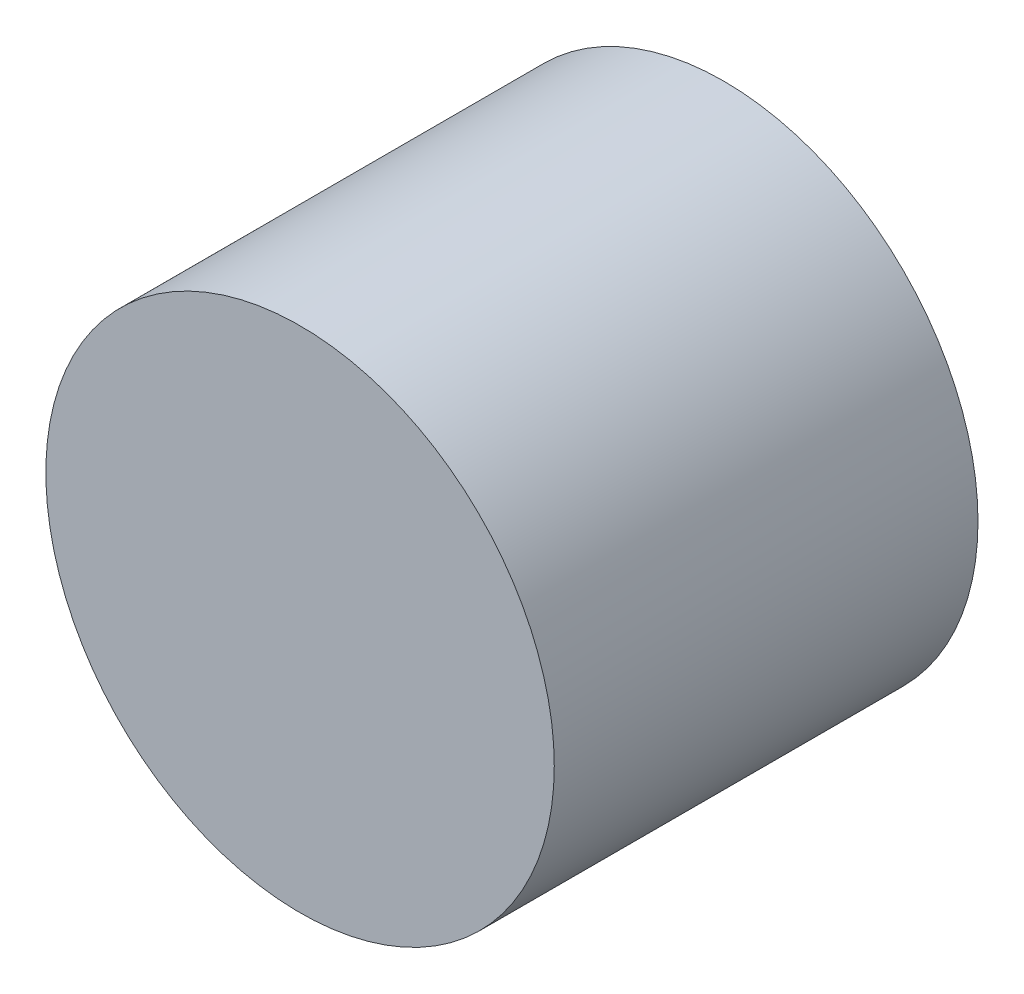
from build123d import *

# Parameters (mm, degrees)
SKETCH1_R      = 6
EXTRUDE2_DEPTH = 10


with BuildPart() as part:
    # Sketch1 → Extrude2 (new body)
    with BuildSketch(Plane.XY):
        with Locations((15, 52.5)):
            Circle(SKETCH1_R)
    extrude(amount=-EXTRUDE2_DEPTH)


solid = part.part
